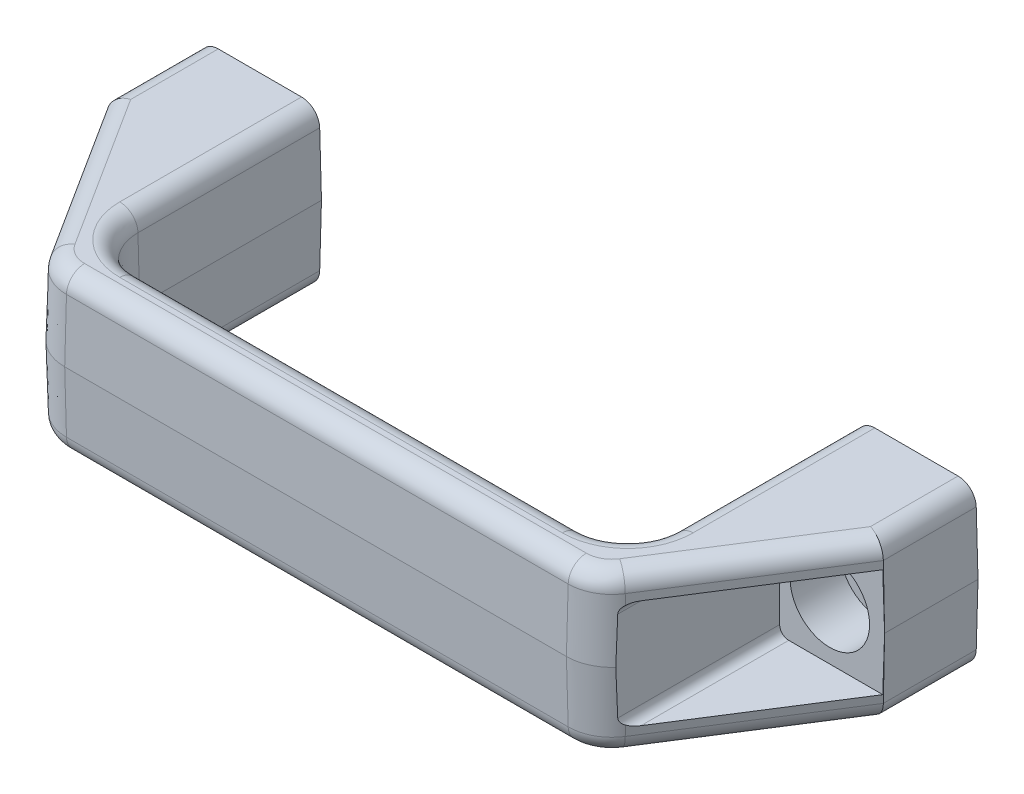
from build123d import *

# Parameters (mm, degrees)
BOSS_EXTRUDE1_START = -11.1125
BOSS_EXTRUDE1_DEPTH = 22.225
CUT_EXTRUDE1_DEPTH  = 26.0444
SKETCH7_R           = 3
CUT_EXTRUDE2_DEPTH  = 39.1000001
SKETCH8_R           = 5.55
CUT_EXTRUDE3_DEPTH  = 6.985
CUT_EXTRUDE4_DEPTH  = 10.5156
FILLET1_R           = 2.54


with BuildPart() as part:
    # Sketch3 → Boss-Extrude1 (new body)
    with BuildSketch(Plane(origin=(0, 0, 0), x_dir=(1, 0, 0), z_dir=(0, 1, 0)).offset(BOSS_EXTRUDE1_START)):
        with BuildLine():
            Line((-30.92525, -31.75), (30.92525, -31.75))
            ThreePointArc((30.92525, -31.75), (35.415378061, -29.890128061), (37.27525, -25.4))
            Line((37.27525, -25.4), (37.27525, 0))
            Line((37.27525, 0), (54.483, 0))
            Line((54.483, 0), (54.483, -13.0556))
            Line((54.483, -13.0556), (40.416702341, -35.159220968))
            ThreePointArc((40.416702341, -35.159220968), (38.115137245, -37.316464459), (35.05949109, -38.1))
            Line((35.05949109, -38.1), (-35.05949109, -38.1))
            ThreePointArc((-35.05949109, -38.1), (-38.115137245, -37.316464459), (-40.416702341, -35.159220968))
            Line((-40.416702341, -35.159220968), (-54.483, -13.0556))
            Line((-54.483, -13.0556), (-54.483, 0))
            Line((-54.483, 0), (-37.27525, 0))
            Line((-37.27525, 0), (-37.27525, -25.4))
            ThreePointArc((-37.27525, -25.4), (-35.415378061, -29.890128061), (-30.92525, -31.75))
        make_face()
    extrude(amount=BOSS_EXTRUDE1_DEPTH)

    # Cut-Sweep1: sweep along a path in Sketch5
    with BuildLine(Plane(origin=(0, 0, 0), x_dir=(1, 0, 0), z_dir=(0, 1, 0))) as cut_sweep1_path:
        Line((-54.483, 0), (-54.483, -13.0556))
        Line((-54.483, -13.0556), (-40.416702341, -35.159220968))
        ThreePointArc((-40.416702341, -35.159220968), (-38.115137245, -37.316464459), (-35.05949109, -38.1))
        Line((-35.05949109, -38.1), (35.05949109, -38.1))
        ThreePointArc((35.05949109, -38.1), (38.115137245, -37.316464459), (40.416702341, -35.159220968))
        Line((40.416702341, -35.159220968), (54.483, -13.0556))
        Line((54.483, -13.0556), (54.483, 0))
    # Sketch4 → Cut-Sweep1 (sweep, cut)
    with BuildSketch(Plane(origin=(0, 0, 0), x_dir=(0, 0, -1), z_dir=(1, 0, 0))):
        Polygon((-38.1, 0), (-37.7825, 11.1125), (-38.1, 11.1125), align=None)
    cut_sweep1 = sweep(path=cut_sweep1_path.line, transition=Transition.RIGHT, mode=Mode.SUBTRACT)

    # Mirror1: Cut-Sweep1 across plane
    add(cut_sweep1.mirror(Plane.ZX), mode=Mode.SUBTRACT)

    # Sketch6 → Cut-Extrude1 (cut, through all)
    with BuildSketch(Plane.XY.offset(13.0556)):
        with BuildLine():
            Line((-54.483, 7.5565), (-41.08525, 7.5565))
            ThreePointArc((-41.08525, 7.5565), (-40.187224388, 7.184525612), (-39.81525, 6.2865))
            Line((-39.81525, 6.2865), (-39.81525, -6.2865))
            ThreePointArc((-39.81525, -6.2865), (-40.187224388, -7.184525612), (-41.08525, -7.5565))
            Line((-41.08525, -7.5565), (-54.483, -7.5565))
            Line((-54.483, -7.5565), (-54.483, 7.5565))
        make_face()
        with BuildLine():
            Line((54.483, 7.5565), (41.08525, 7.5565))
            ThreePointArc((41.08525, 7.5565), (40.187224388, 7.184525612), (39.81525, 6.2865))
            Line((39.81525, 6.2865), (39.81525, -6.2865))
            ThreePointArc((39.81525, -6.2865), (40.187224388, -7.184525612), (41.08525, -7.5565))
            Line((41.08525, -7.5565), (54.483, -7.5565))
            Line((54.483, -7.5565), (54.483, 7.5565))
        make_face()
    extrude(amount=CUT_EXTRUDE1_DEPTH, mode=Mode.SUBTRACT)

    # Sketch7 → Cut-Extrude2 (cut, through all)
    with BuildSketch(Plane.XY):
        with Locations((-46.83125, 0)):
            Circle(SKETCH7_R)
        with Locations((46.83125, 0)):
            Circle(SKETCH7_R)
    extrude(amount=CUT_EXTRUDE2_DEPTH, mode=Mode.SUBTRACT)

    # Sketch8 → Cut-Extrude3 (cut)
    with BuildSketch(Plane.XY.offset(13.0556)):
        with Locations((-46.83125, 0)):
            Circle(SKETCH8_R)
        with Locations((46.83125, 0)):
            Circle(SKETCH8_R)
    extrude(amount=-CUT_EXTRUDE3_DEPTH, mode=Mode.SUBTRACT)

    # Cut-Sweep2: sweep along a path in Sketch10
    with BuildLine(Plane(origin=(0, 0, 0), x_dir=(1, 0, 0), z_dir=(0, 1, 0))) as cut_sweep2_path:
        Line((-37.27525, 0), (-37.27525, -25.4))
        ThreePointArc((-37.27525, -25.4), (-35.415378061, -29.890128061), (-30.92525, -31.75))
        Line((-30.92525, -31.75), (30.92525, -31.75))
        ThreePointArc((30.92525, -31.75), (35.415378061, -29.890128061), (37.27525, -25.4))
        Line((37.27525, -25.4), (37.27525, 0))
    # Sketch9 → Cut-Sweep2 (sweep, cut)
    with BuildSketch(Plane(origin=(0, 0, 0), x_dir=(0, 0, -1), z_dir=(1, 0, 0))):
        Polygon((-31.75, 11.1125), (-31.75, 0), (-32.0675, 11.1125), align=None)
    cut_sweep2 = sweep(path=cut_sweep2_path.line, mode=Mode.SUBTRACT)

    # Mirror2: Cut-Sweep2 across plane
    add(cut_sweep2.mirror(Plane.ZX), mode=Mode.SUBTRACT)

    # Sketch11 → Cut-Extrude4 (cut)
    with BuildSketch(Plane.XY):
        with BuildLine():
            Line((-39.964326287, 5.181391724), (-40.043590393, 7.955635456))
            ThreePointArc((-40.043590393, 7.955635456), (-40.23577686, 8.39287952), (-40.678331368, 8.5725))
            Line((-40.678331368, 8.5725), (-51.079918632, 8.5725))
            ThreePointArc((-51.079918632, 8.5725), (-51.52247314, 8.39287952), (-51.714659607, 7.955635456))
            Line((-51.714659607, 7.955635456), (-51.793923713, 5.181391724))
            ThreePointArc((-51.793923713, 5.181391724), (-51.407275524, 4.578726568), (-50.70517642, 4.719293135))
            ThreePointArc((-50.70517642, 4.719293135), (-45.879125, 6.75), (-41.05307358, 4.719293135))
            ThreePointArc((-41.05307358, 4.719293135), (-40.350974476, 4.578726568), (-39.964326287, 5.181391724))
        make_face()
        with BuildLine():
            Line((40.043590393, 7.955635456), (39.964326287, 5.181391724))
            ThreePointArc((39.964326287, 5.181391724), (40.350974476, 4.578726568), (41.05307358, 4.719293135))
            ThreePointArc((41.05307358, 4.719293135), (45.879125, 6.75), (50.70517642, 4.719293135))
            ThreePointArc((50.70517642, 4.719293135), (51.407275524, 4.578726568), (51.793923713, 5.181391724))
            Line((51.793923713, 5.181391724), (51.714659607, 7.955635456))
            ThreePointArc((51.714659607, 7.955635456), (51.52247314, 8.39287952), (51.079918632, 8.5725))
            Line((51.079918632, 8.5725), (40.678331368, 8.5725))
            ThreePointArc((40.678331368, 8.5725), (40.23577686, 8.39287952), (40.043590393, 7.955635456))
        make_face()
        with BuildLine():
            Line((40.043590393, -7.955635456), (39.964326287, -5.181391724))
            ThreePointArc((39.964326287, -5.181391724), (40.350974476, -4.578726568), (41.05307358, -4.719293135))
            ThreePointArc((41.05307358, -4.719293135), (45.879125, -6.75), (50.70517642, -4.719293135))
            ThreePointArc((50.70517642, -4.719293135), (51.407275524, -4.578726568), (51.793923713, -5.181391724))
            Line((51.793923713, -5.181391724), (51.714659607, -7.955635456))
            ThreePointArc((51.714659607, -7.955635456), (51.52247314, -8.39287952), (51.079918632, -8.5725))
            Line((51.079918632, -8.5725), (40.678331368, -8.5725))
            ThreePointArc((40.678331368, -8.5725), (40.23577686, -8.39287952), (40.043590393, -7.955635456))
        make_face()
        with BuildLine():
            Line((-51.793923713, -5.181391724), (-51.714659607, -7.955635456))
            ThreePointArc((-51.714659607, -7.955635456), (-51.52247314, -8.39287952), (-51.079918632, -8.5725))
            Line((-51.079918632, -8.5725), (-40.678331368, -8.5725))
            ThreePointArc((-40.678331368, -8.5725), (-40.23577686, -8.39287952), (-40.043590393, -7.955635456))
            Line((-40.043590393, -7.955635456), (-39.964326287, -5.181391724))
            ThreePointArc((-39.964326287, -5.181391724), (-40.350974476, -4.578726568), (-41.05307358, -4.719293135))
            ThreePointArc((-41.05307358, -4.719293135), (-45.879125, -6.75), (-50.70517642, -4.719293135))
            ThreePointArc((-50.70517642, -4.719293135), (-51.407275524, -4.578726568), (-51.793923713, -5.181391724))
        make_face()
    extrude(amount=CUT_EXTRUDE4_DEPTH, mode=Mode.SUBTRACT)

    # Fillet1
    fillet1_edges = [part.edges().sort_by_distance(p)[0] for p in [
        (37.59275, 11.1125, 12.7),
        (35.639884464, 11.1125, 30.114634464),
        (0, 11.1125, 32.0675),
        (-35.639884464, 11.1125, 30.114634464),
        (-37.59275, 11.1125, 12.7),
        (37.59275, -11.1125, 12.7),
        (35.639884464, -11.1125, 30.114634464),
        (0, -11.1125, 32.0675),
        (-35.639884464, -11.1125, 30.114634464),
        (-37.59275, -11.1125, 12.7),
        (-54.1655, 11.1125, 6.481570901),
        (47.157170889, 11.1125, 23.975950861),
        (37.962354937, 11.1125, 37.038141236),
        (0, 11.1125, 37.7825),
        (-37.962354937, 11.1125, 37.038141236),
        (-47.157170889, 11.1125, 23.975950861),
        (54.1655, 11.1125, 6.481570901),
        (-54.1655, -11.1125, 6.481570901),
        (47.157170889, -11.1125, 23.975950861),
        (37.962354937, -11.1125, 37.038141236),
        (0, -11.1125, 37.7825),
        (-37.962354937, -11.1125, 37.038141236),
        (-47.157170889, -11.1125, 23.975950861),
        (54.1655, -11.1125, 6.481570901),
    ]]
    fillet(fillet1_edges, radius=FILLET1_R)


solid = part.part
